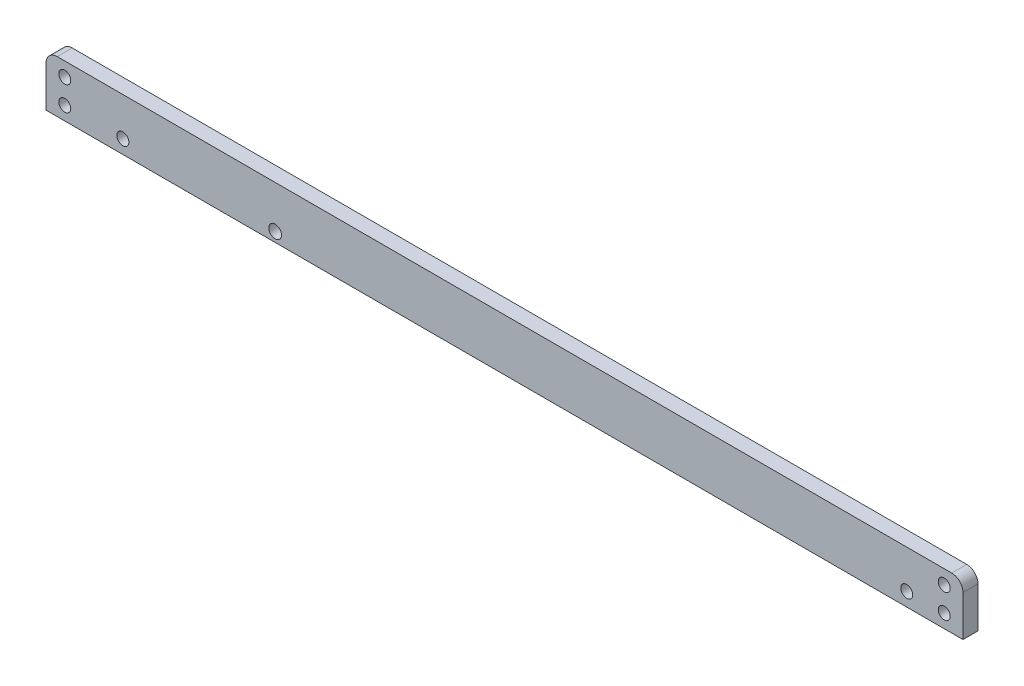
from build123d import *

# Parameters (mm, degrees)
BOSS_EXTRUDE1_DEPTH  = 4
M3_CLEARANCE_HOLE1_D = 3.2
M3_CLEARANCE_HOLE2_D = 3.4


with BuildPart() as part:
    # Sketch1 → Boss-Extrude1 (new body)
    with BuildSketch(Plane.XY):
        with BuildLine():
            Line((59.571068699, 89.405091171), (-178.928931301, 89.405091171))
            ThreePointArc((-178.928931301, 89.405091171), (-181.050251645, 88.526411514), (-181.928931301, 86.405091171))
            Line((-181.928931301, 86.405091171), (-181.928931301, 75.539261619))
            Line((-181.928931301, 75.539261619), (62.571068699, 75.539261619))
            Line((62.571068699, 75.539261619), (62.571068699, 86.405091171))
            ThreePointArc((62.571068699, 86.405091171), (61.692389042, 88.526411514), (59.571068699, 89.405091171))
        make_face()
    extrude(amount=BOSS_EXTRUDE1_DEPTH)

    # M3 Clearance Hole1 (through all)
    with Locations(Plane.XY.offset(4)):
        with Locations((-176.928931301, 85.672841171), (-176.928931301, 79.172841171), (-161.428931301, 79.172841171), (47.571068699, 79.172841171), (57.571068699, 79.172841171), (57.571068699, 85.672841171)):
            Hole(M3_CLEARANCE_HOLE1_D / 2)

    # M3 Clearance Hole2 (through all)
    with Locations(Plane(origin=(0, 0, 0), x_dir=(-1, 0, 0), z_dir=(0, 0, -1))):
        with Locations((120.8322952, 78.075091171)):
            Hole(M3_CLEARANCE_HOLE2_D / 2)


solid = part.part
